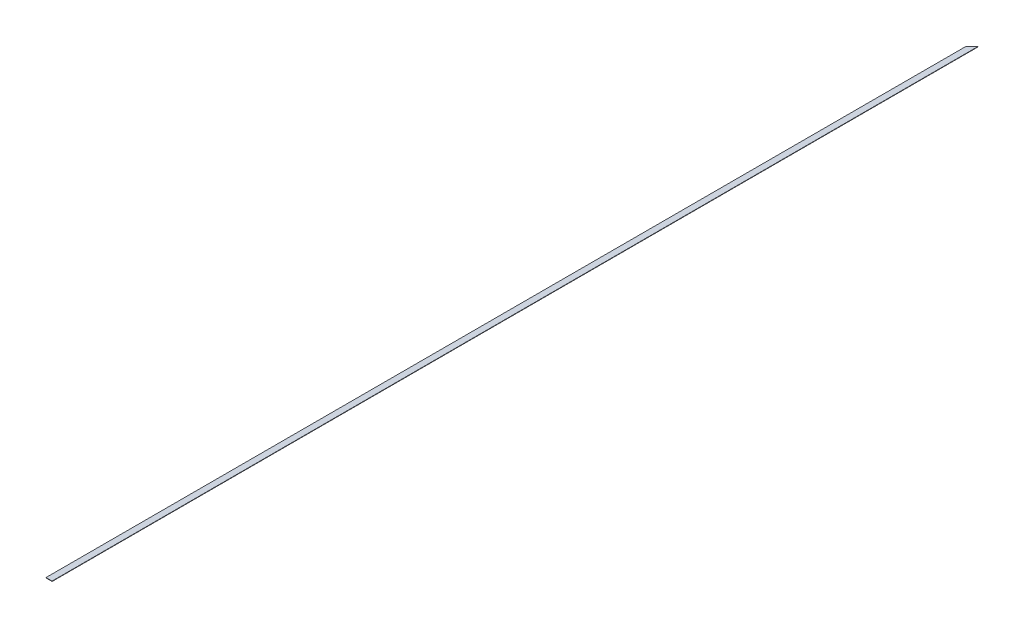
from build123d import *

# Parameters (mm, degrees)
BOSS_EXTRUDE1_DEPTH = 3.175


with BuildPart() as part:
    # Sketch1 → Boss-Extrude1 (new body)
    with BuildSketch(Plane(origin=(0, 0, 0), x_dir=(1, 0, 0), z_dir=(0, 1, 0))):
        Polygon((-25.31589404, 3810.04205298), (25.48410596, 3860.84205298), (25.48410596, -3835.35794702), (-25.31589404, -3835.35794702), align=None)
    extrude(amount=BOSS_EXTRUDE1_DEPTH)


solid = part.part
